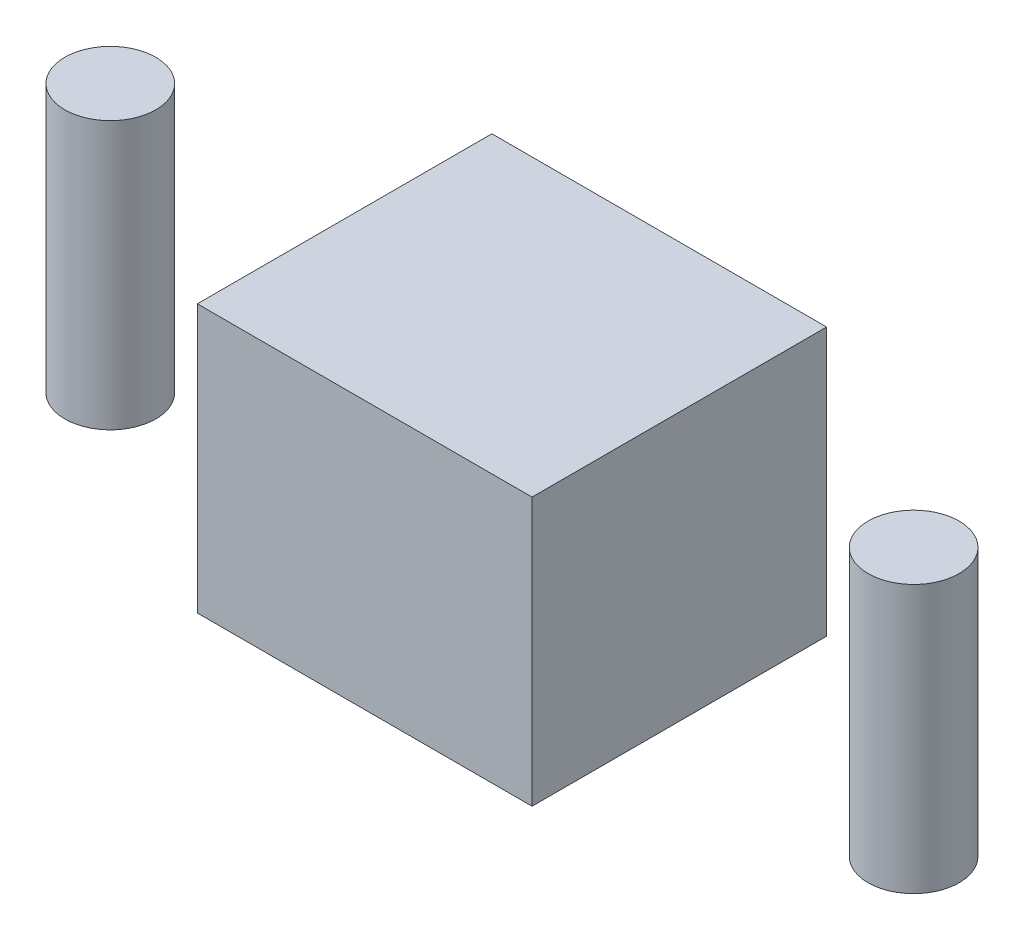
from build123d import *

# Parameters (mm, degrees)
SKETCH2_R             = 1.7
BOSS_EXTRUDE1_DEPTH   = 10
BOSS_EXTRUDE1_2_DEPTH = 10
SKETCH2_W             = 12.5
SKETCH2_H             = 11
BOSS_EXTRUDE1_3_DEPTH = 10


with BuildPart() as part:
    # Sketch2 → Boss-Extrude1 (new body)
    with BuildSketch(Plane(origin=(0, 0, 0), x_dir=(1, 0, 0), z_dir=(0, 1, 0))):
        with Locations((15, 0)):
            Circle(SKETCH2_R)
    extrude(amount=BOSS_EXTRUDE1_DEPTH)


with BuildPart() as body_2:
    # Sketch2 → Boss-Extrude1 2 (new body)
    with BuildSketch(Plane(origin=(0, 0, 0), x_dir=(1, 0, 0), z_dir=(0, 1, 0))):
        with Locations((-15, 0)):
            Circle(SKETCH2_R)
    extrude(amount=BOSS_EXTRUDE1_2_DEPTH)


with BuildPart() as body_3:
    # Sketch2 → Boss-Extrude1 3 (new body)
    with BuildSketch(Plane(origin=(0, 0, 0), x_dir=(1, 0, 0), z_dir=(0, 1, 0))):
        Rectangle(SKETCH2_W, SKETCH2_H)
    extrude(amount=BOSS_EXTRUDE1_3_DEPTH)


solid = Compound([part.part, body_2.part, body_3.part])
